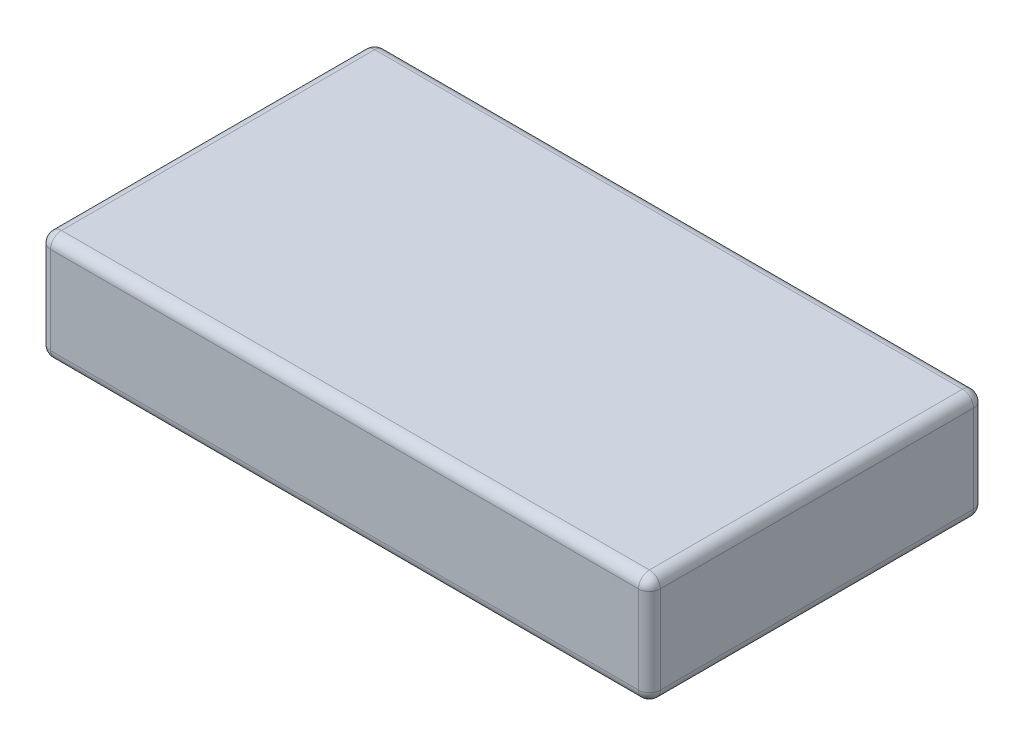
from build123d import *

# Parameters (mm, degrees)
SKETCH1_W           = 55.7
SKETCH1_H           = 30.6
BOSS_EXTRUDE1_DEPTH = 10
FILLET1_R           = 1


with BuildPart() as part:
    # Sketch1 → Boss-Extrude1 (new body)
    with BuildSketch(Plane(origin=(0, 0, 0), x_dir=(1, 0, 0), z_dir=(0, 1, 0))):
        with Locations((27.85, 15.3)):
            Rectangle(SKETCH1_W, SKETCH1_H)
    extrude(amount=BOSS_EXTRUDE1_DEPTH)

    # Fillet1
    fillet1_edges = [part.edges().sort_by_distance(p)[0] for p in [
        (55.7, 10, -15.3),
        (27.85, 10, -30.6),
        (0, 10, -15.3),
        (27.85, 0, -30.6),
        (55.7, 0, -15.3),
        (27.85, 0, 0),
        (0, 0, -15.3),
        (27.85, 10, 0),
        (0, 5, -30.6),
        (55.7, 5, -30.6),
        (55.7, 5, 0),
        (0, 5, 0),
    ]]
    fillet(fillet1_edges, radius=FILLET1_R)


solid = part.part
